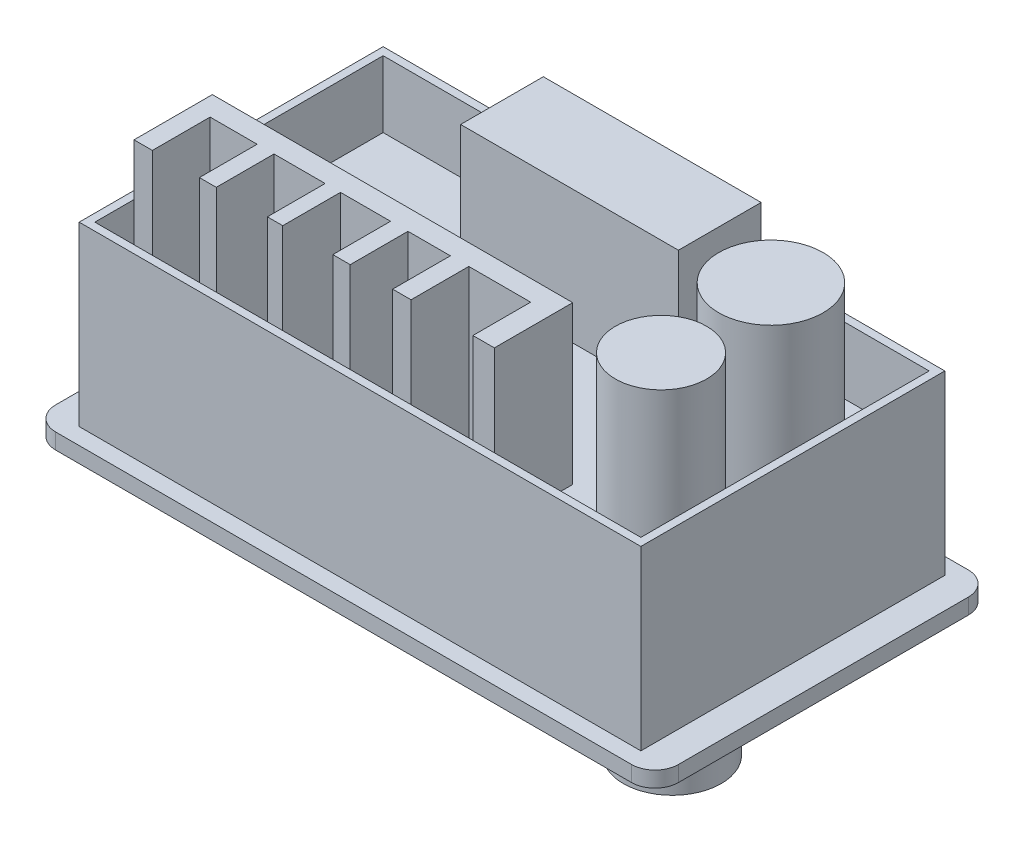
from build123d import *

# Parameters (mm, degrees)
SKETCH1_W           = 79.5
SKETCH1_H           = 43
BOSS_EXTRUDE1_DEPTH = 2
SKETCH2_W           = 71.7
SKETCH2_H           = 38.8
BOSS_EXTRUDE2_DEPTH = 22.6
SKETCH3_W           = 69.7
SKETCH3_H           = 36.8
CUT_EXTRUDE1_DEPTH  = 8.5
BOSS_EXTRUDE3_DEPTH = 22.6
SKETCH6_W           = 67.219676188
SKETCH6_H           = 8.940869551
CUT_EXTRUDE2_DEPTH  = 22.6
SKETCH7_R           = 6.66374012
SKETCH7_R_2         = 5.829163104
BOSS_EXTRUDE4_DEPTH = 20.1
FILLET1_R           = 3
SKETCH8_W           = 27.801535977
SKETCH8_H           = 10.55826339
BOSS_EXTRUDE5_DEPTH = 17
SKETCH9_W           = 67.5
SKETCH9_H           = 31
CUT_EXTRUDE3_DEPTH  = 1
SKETCH10_W          = 28.845725121
SKETCH10_H          = 25.974204973
CUT_EXTRUDE4_DEPTH  = 1
SKETCH11_R          = 6.25
BOSS_EXTRUDE6_DEPTH = 12


with BuildPart() as part:
    # Sketch1 → Boss-Extrude1 (new body)
    with BuildSketch(Plane(origin=(0, 0, 0), x_dir=(1, 0, 0), z_dir=(0, 1, 0))):
        with Locations((25.074854651, -17.802325581)):
            Rectangle(SKETCH1_W, SKETCH1_H)
    extrude(amount=BOSS_EXTRUDE1_DEPTH)

    # Sketch2 → Boss-Extrude2 (add)
    with BuildSketch(Plane(origin=(0, 2, 0), x_dir=(1, 0, 0), z_dir=(0, 1, 0))):
        with Locations((25.074854651, -17.802325581)):
            Rectangle(SKETCH2_W, SKETCH2_H)
    extrude(amount=BOSS_EXTRUDE2_DEPTH)

    # Sketch3 → Cut-Extrude1 (cut)
    with BuildSketch(Plane(origin=(0, 24.6, 0), x_dir=(1, 0, 0), z_dir=(0, 1, 0))):
        with Locations((25.074854651, -17.802325581)):
            Rectangle(SKETCH3_W, SKETCH3_H)
    extrude(amount=-CUT_EXTRUDE1_DEPTH, mode=Mode.SUBTRACT)

    # Sketch5 → Boss-Extrude3 (add)
    with BuildSketch(Plane(origin=(0, 16.1, 0), x_dir=(1, 0, 0), z_dir=(0, 1, 0))):
        Polygon((41.224854651, -26.202325581), (-4.775145349, -26.202325581), (-4.775145349, -36.202325581), (-2.433003128, -36.202325581), (-2.433003128, -28.831573422), (3.571084453, -28.831573422), (3.571084453, -36.202325581), (5.724724564, -36.202325581), (5.724724564, -28.831573422), (12.250906718, -28.831573422), (12.250906718, -36.202325581), (14.208761365, -36.202325581), (14.208761365, -28.831573422), (20.604419876, -28.831573422), (20.604419876, -36.202325581), (22.823321808, -36.202325581), (22.823321808, -28.831573422), (28.240052996, -28.831573422), (28.240052996, -36.202325581), (30.589478571, -36.202325581), (30.589478571, -28.831573422), (38.486158978, -28.831573422), (38.486158978, -36.202325581), (41.224854651, -36.202325581), align=None)
    extrude(amount=BOSS_EXTRUDE3_DEPTH)

    # Sketch6 → Cut-Extrude2 (cut)
    with BuildSketch(Plane.XY.offset(37.202325581)):
        with Locations((18.972874337, 40.670434775)):
            Rectangle(SKETCH6_W, SKETCH6_H)
    extrude(amount=-CUT_EXTRUDE2_DEPTH, mode=Mode.SUBTRACT)

    # Sketch7 → Boss-Extrude4 (add)
    with BuildSketch(Plane(origin=(0, 16.1, 0), x_dir=(1, 0, 0), z_dir=(0, 1, 0))):
        with Locations((51.669046929, -11.341405249)):
            Circle(SKETCH7_R)
        with Locations((52.386926966, -26.090576917)):
            Circle(SKETCH7_R_2)
    extrude(amount=BOSS_EXTRUDE4_DEPTH)

    # Fillet1
    fillet1_edges = [part.edges().sort_by_distance(p)[0] for p in [
        (-14.675145349, 1, -3.697674419),
        (64.824854651, 1, -3.697674419),
        (64.824854651, 1, 39.302325581),
        (-14.675145349, 1, 39.302325581),
    ]]
    fillet(fillet1_edges, radius=FILLET1_R)

    # Sketch8 → Boss-Extrude5 (add)
    with BuildSketch(Plane(origin=(0, 16.1, 0), x_dir=(1, 0, 0), z_dir=(0, 1, 0))):
        with Locations((25.172747384, -5.279131695)):
            Rectangle(SKETCH8_W, SKETCH8_H)
    extrude(amount=BOSS_EXTRUDE5_DEPTH)

    # Sketch9 → Cut-Extrude3 (cut)
    with BuildSketch(Plane.XZ):
        with Locations((25.074854651, 17.802325581)):
            Rectangle(SKETCH9_W, SKETCH9_H)
    extrude(amount=-CUT_EXTRUDE3_DEPTH, mode=Mode.SUBTRACT)

    # Sketch10 → Cut-Extrude4 (cut)
    with BuildSketch(Plane.XZ.offset(-1)):
        with Locations((18.581303408, 17.606540116)):
            Rectangle(SKETCH10_W, SKETCH10_H)
    extrude(amount=-CUT_EXTRUDE4_DEPTH, mode=Mode.SUBTRACT)

    # Sketch11 → Boss-Extrude6 (add)
    with BuildSketch(Plane.XZ.offset(-1)):
        with Locations((50.42907232, 22.696962197)):
            Circle(SKETCH11_R)
    extrude(amount=BOSS_EXTRUDE6_DEPTH)


solid = part.part
